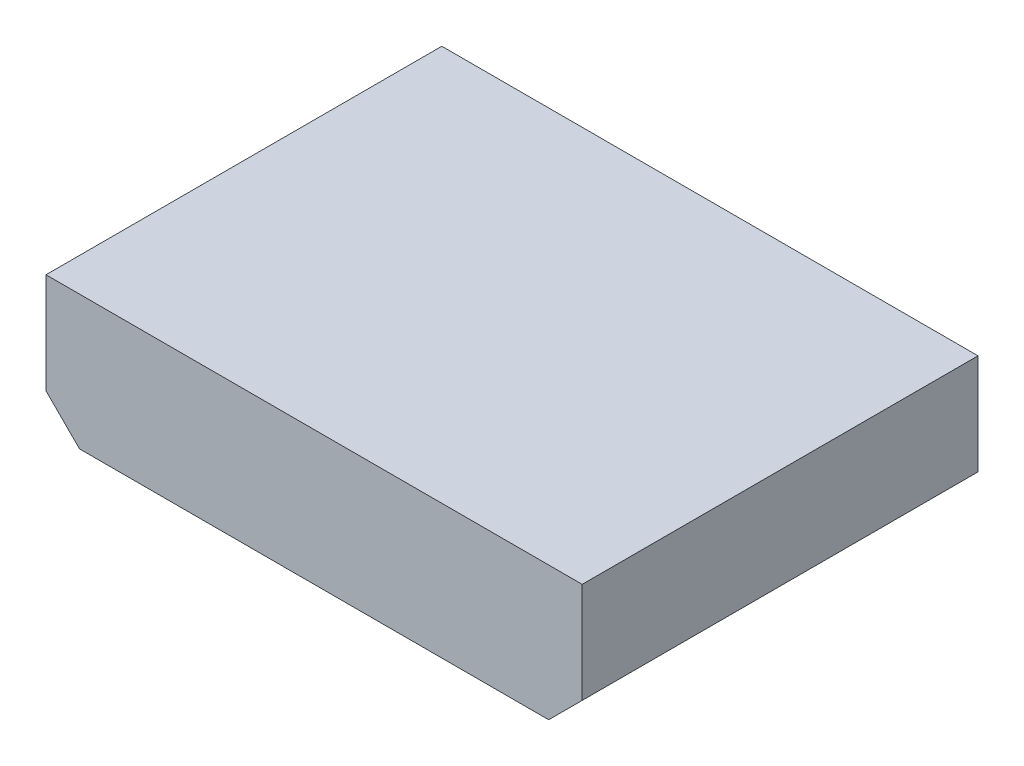
from build123d import *

# Parameters (mm, degrees)
COMPONENT_OUTLINE_DEPTH = 15
SKETCH2_R               = 0.25
EXTRUDE_1_DEPTH         = 2
SKETCH3_R               = 0.25
EXTRUDE_2_DEPTH         = 2
SKETCH4_R               = 0.25
EXTRUDE_3_DEPTH         = 2
SKETCH5_R               = 0.25
EXTRUDE_4_DEPTH         = 2
SKETCH6_R               = 0.25
EXTRUDE_5_DEPTH         = 2


with BuildPart() as part:
    # Sketch1 → Component_Outline (new body)
    with BuildSketch(Plane.XY):
        Polygon((-5.08, 2.54), (-5.08, -1.27), (-3.81, -2.54), (13.97, -2.54), (15.24, -1.27), (15.24, 2.54), align=None)
    extrude(amount=COMPONENT_OUTLINE_DEPTH)


with BuildPart() as body_2:
    # Sketch2 → Extrude 1 (new body)
    with BuildSketch(Plane.XY):
        Circle(SKETCH2_R)
    extrude(amount=-EXTRUDE_1_DEPTH)


with BuildPart() as body_3:
    # Sketch3 → Extrude 2 (new body)
    with BuildSketch(Plane.XY):
        with Locations((2.54, 0)):
            Circle(SKETCH3_R)
    extrude(amount=-EXTRUDE_2_DEPTH)


with BuildPart() as body_4:
    # Sketch4 → Extrude 3 (new body)
    with BuildSketch(Plane.XY):
        with Locations((5.08, 0)):
            Circle(SKETCH4_R)
    extrude(amount=-EXTRUDE_3_DEPTH)


with BuildPart() as body_5:
    # Sketch5 → Extrude 4 (new body)
    with BuildSketch(Plane.XY):
        with Locations((7.62, 0)):
            Circle(SKETCH5_R)
    extrude(amount=-EXTRUDE_4_DEPTH)


with BuildPart() as body_6:
    # Sketch6 → Extrude 5 (new body)
    with BuildSketch(Plane.XY):
        with Locations((10.16, 0)):
            Circle(SKETCH6_R)
    extrude(amount=-EXTRUDE_5_DEPTH)


solid = Compound([part.part, body_2.part, body_3.part, body_4.part, body_5.part, body_6.part])
